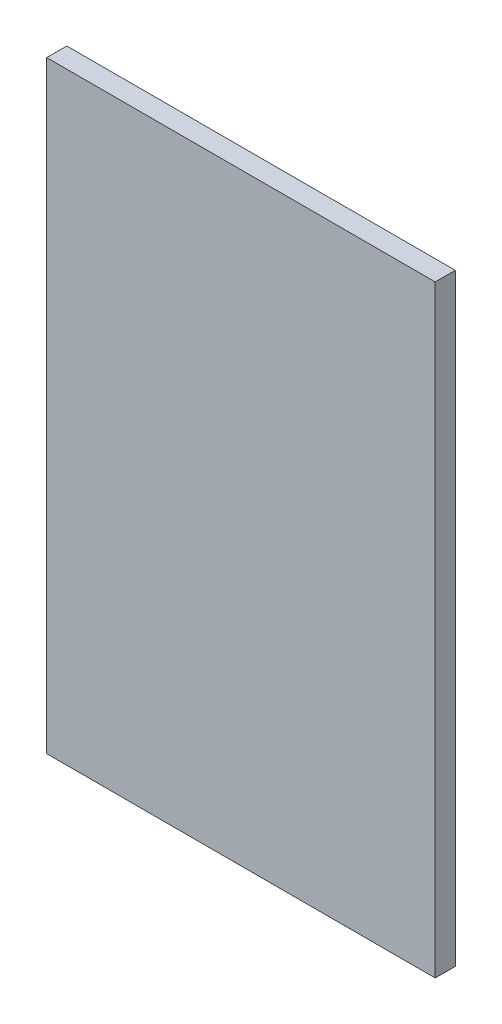
from build123d import *

# Parameters (mm, degrees)
ESQUISSE1_W        = 58
ESQUISSE1_H        = 90
BOSS_EXTRU_1_DEPTH = 3


with BuildPart() as part:
    # Esquisse1 → Boss.-Extru.1 (new body)
    with BuildSketch(Plane.XY):
        with Locations((29, -45)):
            Rectangle(ESQUISSE1_W, ESQUISSE1_H)
    extrude(amount=BOSS_EXTRU_1_DEPTH)


solid = part.part
